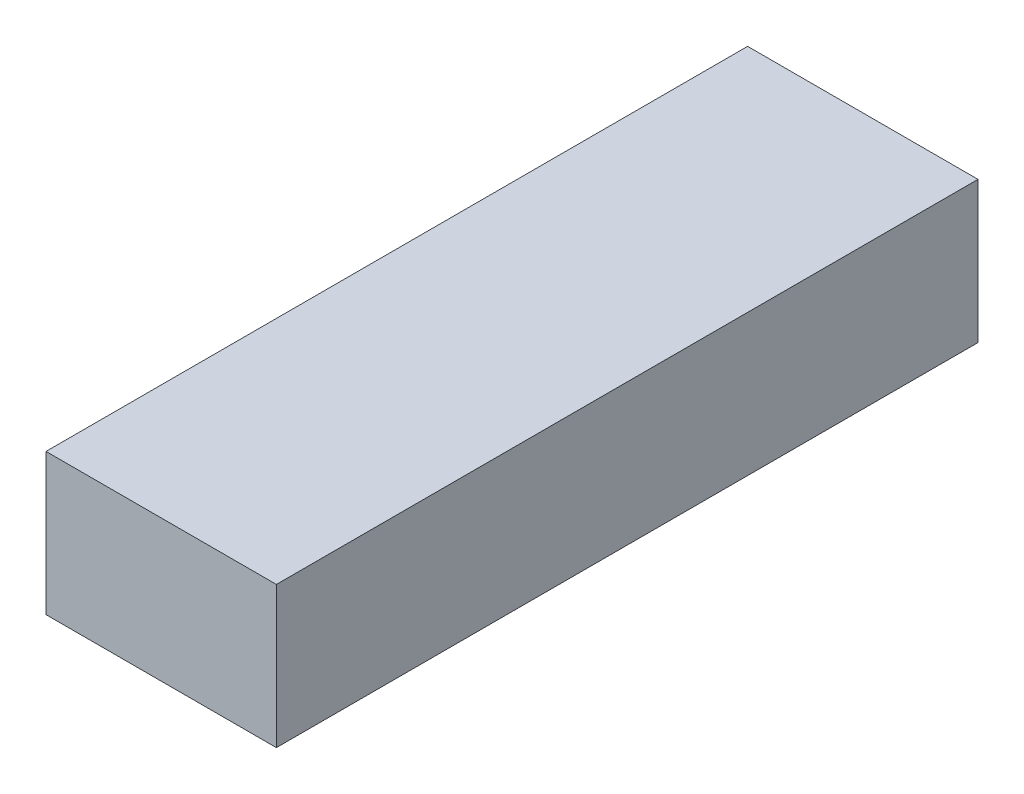
from build123d import *

# Parameters (mm, degrees)
SKETCH1_W           = 44
SKETCH1_H           = 27
BOSS_EXTRUDE1_DEPTH = 134


with BuildPart() as part:
    # Sketch1 → Boss-Extrude1 (new body)
    with BuildSketch(Plane.XY):
        Rectangle(SKETCH1_W, SKETCH1_H)
    extrude(amount=BOSS_EXTRUDE1_DEPTH)


solid = part.part
